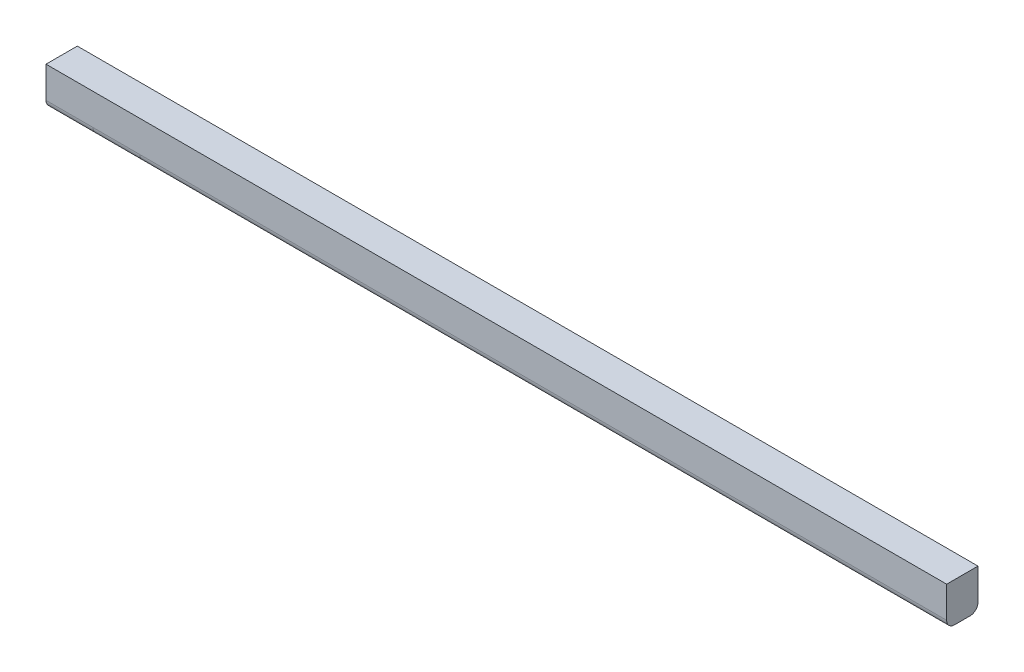
from build123d import *

# Parameters (mm, degrees)
SKIZZE1_W                       = 4
SKIZZE1_H                       = 5
AUFSATZ_LINEAR_AUSTRAGEN1_DEPTH = 115
VERRUNDUNG1_R                   = 1


with BuildPart() as part:
    # Skizze1 → Aufsatz-Linear austragen1 (new body)
    with BuildSketch(Plane(origin=(0, 0, 0), x_dir=(0, 0, -1), z_dir=(1, 0, 0))):
        with Locations((-1, -2.5)):
            Rectangle(SKIZZE1_W, SKIZZE1_H)
    extrude(amount=AUFSATZ_LINEAR_AUSTRAGEN1_DEPTH)

    # Verrundung1
    verrundung1_edges = [part.edges().sort_by_distance(p)[0] for p in [
        (57.5, -5, -1),
        (57.5, -5, 3),
    ]]
    fillet(verrundung1_edges, radius=VERRUNDUNG1_R)


solid = part.part
